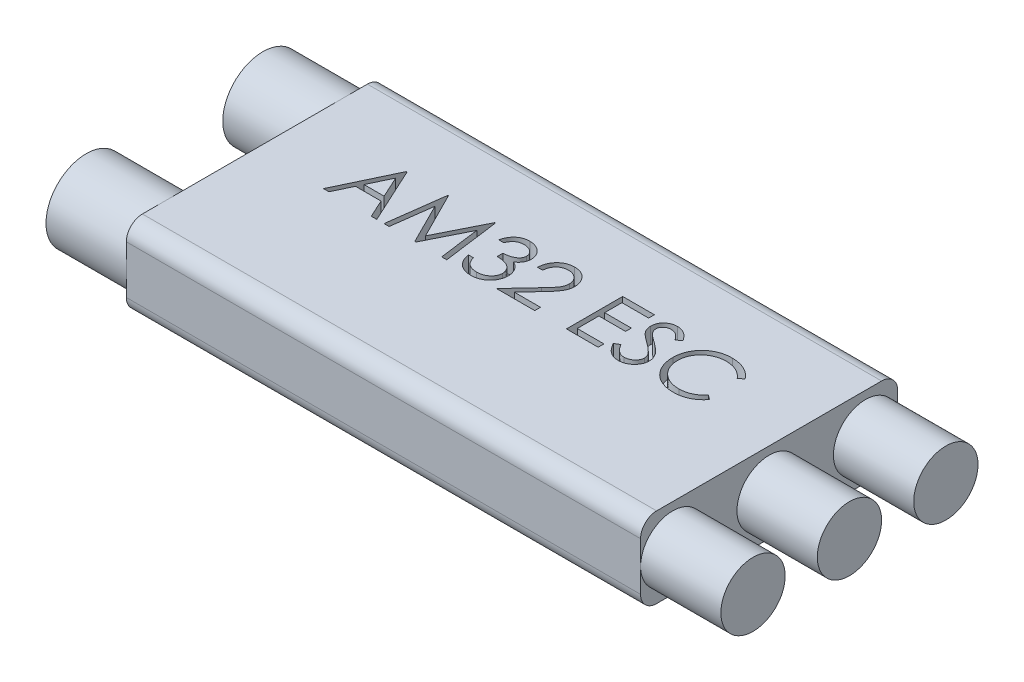
from build123d import *

# Parameters (mm, degrees)
SKETCH1_W           = 32
SKETCH1_H           = 16
BOSS_EXTRUDE1_DEPTH = 5
CUT_EXTRUDE1_DEPTH  = 1
SKETCH3_R           = 2
BOSS_EXTRUDE2_DEPTH = 5
SKETCH4_R           = 2.5
BOSS_EXTRUDE3_DEPTH = 5
FILLET1_R           = 1


with BuildPart() as part:
    # Sketch1 → Boss-Extrude1 (new body)
    with BuildSketch(Plane(origin=(0, 0, 0), x_dir=(1, 0, 0), z_dir=(0, 1, 0))):
        Rectangle(SKETCH1_W, SKETCH1_H)
    extrude(amount=BOSS_EXTRUDE1_DEPTH)

    # Sketch2 → Cut-Extrude1 (cut)
    with BuildSketch(Plane(origin=(0, 5, 0), x_dir=(1, 0, 0), z_dir=(0, 1, 0))):
        Polygon((-10.028846154, 3.5), (-8.413461538, 0), (-8.754907853, 0), (-9.272335737, 1.121794872), (-10.858974359, 1.121794872), (-11.391125801, 0), (-11.733974359, 0), (-10.073717949, 3.5), align=None)
        Polygon((-10.05478766, 2.817808494), (-10.688601763, 1.480769231), (-9.437800481, 1.480769231), align=None, mode=Mode.SUBTRACT)
        Polygon((-7.96474359, 0), (-7.502704327, 3.5), (-7.457832532, 3.5), (-6.012820513, 0.628205128), (-4.571314103, 3.5), (-4.525741186, 3.5), (-4.060897436, 0), (-4.376402244, 0), (-4.711538462, 2.518429487), (-5.974959936, 0), (-6.045773237, 0), (-7.314102564, 2.524038462), (-7.64853766, 0), align=None)
        with BuildLine():
            Line((-3.208333333, 2.692307692), (-3.522435897, 2.692307692))
            add(Edge.make_bspline(
                [(-3.522435897, 2.692307692), (-3.513926347, 2.727540176), (-3.497290871, 2.796416801), (-3.462593298, 2.894824062), (-3.424794043, 2.987947583), (-3.379404938, 3.074043657), (-3.329896184, 3.154842559), (-3.273173462, 3.228511684), (-3.21185374, 3.296924649), (-3.14402879, 3.357637887), (-3.072900129, 3.412615616), (-2.997465509, 3.459490673), (-2.919242615, 3.499814826), (-2.837689482, 3.533035058), (-2.752563311, 3.558060582), (-2.664633687, 3.576217387), (-2.573670187, 3.588008502), (-2.511922597, 3.589159265), (-2.48056891, 3.58974359)],
                knots=[0, 0, 0, 0, 0.000108665, 0.000212431, 0.000312691, 0.000409905, 0.000504067, 0.000596618, 0.000688443, 0.000779278, 0.000869306, 0.00095782, 0.001045306, 0.001133058, 0.001221569, 0.001311085, 0.001402223, 0.001496238, 0.001496238, 0.001496238, 0.001496238], degree=3))
            add(Edge.make_bspline(
                [(-2.48056891, 3.58974359), (-2.434886168, 3.588364359), (-2.344517157, 3.585635984), (-2.21175411, 3.560721548), (-2.083727291, 3.521296415), (-1.961838043, 3.466822688), (-1.848619611, 3.399635375), (-1.747883424, 3.319670638), (-1.660994913, 3.228471337), (-1.588100536, 3.127738772), (-1.531025537, 3.020083263), (-1.488939163, 2.909283106), (-1.463317482, 2.795601134), (-1.459996925, 2.718843855), (-1.458333333, 2.680388622)],
                knots=[0, 0, 0, 0, 0.000136936, 0.000270885, 0.000403723, 0.000538055, 0.000670441, 0.000797677, 0.000922646, 0.001047185, 0.00116951, 0.001287103, 0.001401935, 0.001517226, 0.001517226, 0.001517226, 0.001517226], degree=3))
            add(Edge.make_bspline(
                [(-1.458333333, 2.680388622), (-1.459496924, 2.643381827), (-1.461773891, 2.570965273), (-1.481107597, 2.465243775), (-1.51364386, 2.365602175), (-1.558713623, 2.271621013), (-1.617055173, 2.183896173), (-1.68772787, 2.102230282), (-1.771230531, 2.026261124), (-1.834509469, 1.982741651), (-1.86708734, 1.960336538)],
                knots=[0, 0, 0, 0, 0.000110957, 0.000217125, 0.000321111, 0.000424595, 0.000528824, 0.000636204, 0.000747885, 0.000866393, 0.000866393, 0.000866393, 0.000866393], degree=3))
            add(Edge.make_bspline(
                [(-1.86708734, 1.960336538), (-1.829855585, 1.942358367), (-1.756088711, 1.906738409), (-1.655538181, 1.836882652), (-1.564260306, 1.756226304), (-1.513356587, 1.693283652), (-1.487780449, 1.661658654)],
                knots=[0, 0, 0, 0, 0.000123863, 0.000245408, 0.000366052, 0.000487879, 0.000487879, 0.000487879, 0.000487879], degree=3))
            add(Edge.make_bspline(
                [(-1.487780449, 1.661658654), (-1.470939106, 1.638600902), (-1.43753221, 1.592862986), (-1.396296677, 1.51932656), (-1.358887562, 1.444975071), (-1.329737343, 1.367815664), (-1.307163476, 1.288742651), (-1.291027444, 1.207620255), (-1.281003303, 1.124382232), (-1.279567751, 1.068069752), (-1.278846154, 1.039763622)],
                knots=[0, 0, 0, 0, 8.5583e-05, 0.000169764, 0.000252544, 0.000335098, 0.000416766, 0.000498992, 0.000583001, 0.000667909, 0.000667909, 0.000667909, 0.000667909], degree=3))
            add(Edge.make_bspline(
                [(-1.278846154, 1.039763622), (-1.280640667, 0.990753901), (-1.284221249, 0.892965099), (-1.316225324, 0.748490377), (-1.365838564, 0.607264875), (-1.4362955, 0.472190036), (-1.522163009, 0.345809655), (-1.624320333, 0.232733346), (-1.741606742, 0.135534741), (-1.872412391, 0.054324513), (-2.014129519, -0.010593409), (-2.165705111, -0.055650852), (-2.324955165, -0.084996852), (-2.434162463, -0.08814372), (-2.489683494, -0.08974359)],
                knots=[0, 0, 0, 0, 0.000146863, 0.000293035, 0.000441833, 0.000594857, 0.000748684, 0.000899086, 0.001050437, 0.001204129, 0.001359752, 0.001516561, 0.001677477, 0.001843893, 0.001843893, 0.001843893, 0.001843893], degree=3))
            add(Edge.make_bspline(
                [(-2.489683494, -0.08974359), (-2.527102794, -0.088875376), (-2.600731499, -0.087167022), (-2.708974997, -0.075488421), (-2.812296697, -0.054158416), (-2.910836295, -0.025455111), (-3.004681331, 0.010936632), (-3.093545436, 0.05625533), (-3.17797533, 0.109566832), (-3.257174281, 0.171500419), (-3.331132848, 0.240781759), (-3.397885573, 0.318640769), (-3.458545366, 0.403638173), (-3.511488004, 0.496761229), (-3.559124957, 0.596806487), (-3.598305914, 0.705054985), (-3.632791482, 0.820539007), (-3.648824947, 0.901016747), (-3.657051282, 0.942307692)],
                knots=[0, 0, 0, 0, 0.000112258, 0.000220887, 0.000326076, 0.000428356, 0.000528479, 0.000627563, 0.000727152, 0.000827569, 0.00092875, 0.001030654, 0.001134734, 0.001241526, 0.001351611, 0.001466743, 0.00158655, 0.001712791, 0.001712791, 0.001712791, 0.001712791], degree=3))
            Line((-3.657051282, 0.942307692), (-3.342948718, 0.942307692))
            add(Edge.make_bspline(
                [(-3.342948718, 0.942307692), (-3.334765427, 0.915358679), (-3.318848214, 0.862940507), (-3.291753916, 0.787500202), (-3.260885644, 0.718342149), (-3.227771085, 0.654959027), (-3.192992639, 0.596726624), (-3.154077714, 0.545184755), (-3.113908569, 0.498069553), (-3.083629215, 0.471524941), (-3.068810096, 0.458533654)],
                knots=[0, 0, 0, 0, 8.4487e-05, 0.000164335, 0.000240293, 0.00031148, 0.000378817, 0.000443461, 0.000505064, 0.000564113, 0.000564113, 0.000564113, 0.000564113], degree=3))
            add(Edge.make_bspline(
                [(-3.068810096, 0.458533654), (-3.04921352, 0.44342532), (-3.010080857, 0.413255288), (-2.946312626, 0.37475366), (-2.87924774, 0.341392634), (-2.807433065, 0.315908939), (-2.732418295, 0.294331278), (-2.65299093, 0.280210759), (-2.569851713, 0.270522587), (-2.513083949, 0.269667656), (-2.484074519, 0.269230769)],
                knots=[0, 0, 0, 0, 7.418e-05, 0.000148131, 0.000223072, 0.000298488, 0.0003764, 0.000456984, 0.000540217, 0.000627201, 0.000627201, 0.000627201, 0.000627201], degree=3))
            add(Edge.make_bspline(
                [(-2.484074519, 0.269230769), (-2.451321017, 0.269846674), (-2.38727437, 0.271051024), (-2.29381951, 0.282126731), (-2.204912063, 0.298257144), (-2.121539137, 0.323170127), (-2.04260863, 0.353950979), (-1.96922698, 0.392599384), (-1.900430874, 0.437944106), (-1.837101468, 0.489483264), (-1.780155961, 0.545904759), (-1.730016448, 0.60491783), (-1.687391786, 0.66627366), (-1.653008208, 0.730311781), (-1.625857658, 0.79676701), (-1.607374457, 0.865825839), (-1.594522942, 0.936923105), (-1.59347633, 0.985252074), (-1.592948718, 1.009615385)],
                knots=[0, 0, 0, 0, 9.822e-05, 0.00019206, 0.00028199, 0.000368957, 0.000452673, 0.000535779, 0.000617257, 0.000699492, 0.000780303, 0.000857417, 0.000931514, 0.001003978, 0.001075065, 0.001146335, 0.001218144, 0.001291145, 0.001291145, 0.001291145, 0.001291145], degree=3))
            add(Edge.make_bspline(
                [(-1.592948718, 1.009615385), (-1.594479019, 1.042226723), (-1.597532008, 1.107287132), (-1.620840587, 1.203004706), (-1.659179452, 1.295228118), (-1.712851963, 1.382383909), (-1.778187692, 1.46315981), (-1.854552598, 1.535231293), (-1.942580827, 1.594701384), (-2.023600696, 1.63579004), (-2.095365852, 1.663827115), (-2.156781237, 1.68250208), (-2.22553784, 1.698315735), (-2.300804189, 1.713028007), (-2.383147405, 1.725549355), (-2.472477843, 1.735991171), (-2.568813605, 1.744346212), (-2.635504771, 1.748077307), (-2.669871795, 1.75)],
                knots=[0, 0, 0, 0, 9.7761e-05, 0.000195035, 0.000293731, 0.000396299, 0.00050098, 0.000604654, 0.000710058, 0.000818548, 0.000876487, 0.000941025, 0.001010919, 0.001088059, 0.001171055, 0.001260716, 0.001357836, 0.001461094, 0.001461094, 0.001461094, 0.001461094], degree=3))
            Line((-2.669871795, 1.75), (-2.669871795, 2.108974359))
            add(Edge.make_bspline(
                [(-2.669871795, 2.108974359), (-2.626570629, 2.109709163), (-2.541754283, 2.111148463), (-2.417859978, 2.128556473), (-2.299386666, 2.152637101), (-2.188959924, 2.189522293), (-2.08831121, 2.23236259), (-2.000991608, 2.2822148), (-1.928224461, 2.337629549), (-1.870363389, 2.399462158), (-1.826834161, 2.465777206), (-1.795007363, 2.534893864), (-1.776207037, 2.607417924), (-1.77369737, 2.656912592), (-1.772435897, 2.681790865)],
                knots=[0, 0, 0, 0, 0.0001298, 0.000254247, 0.000374709, 0.000491998, 0.000602842, 0.000702416, 0.000792872, 0.000876214, 0.000955164, 0.001029842, 0.001103644, 0.00117823, 0.00117823, 0.00117823, 0.00117823], degree=3))
            add(Edge.make_bspline(
                [(-1.772435897, 2.681790865), (-1.772850308, 2.700068611), (-1.773674759, 2.736431318), (-1.784072037, 2.789556386), (-1.799696078, 2.841057332), (-1.821175807, 2.890715142), (-1.849926006, 2.938185416), (-1.884331993, 2.983872865), (-1.925300093, 3.027516644), (-1.97224554, 3.068196964), (-2.022657345, 3.106966201), (-2.07790712, 3.139879838), (-2.136328995, 3.1680249), (-2.19798765, 3.191234402), (-2.26308318, 3.20869369), (-2.331309737, 3.221229532), (-2.402797421, 3.229067187), (-2.451569153, 3.230195602), (-2.476362179, 3.230769231)],
                knots=[0, 0, 0, 0, 5.4759e-05, 0.000108941, 0.000161726, 0.000216044, 0.000270754, 0.000327825, 0.00038735, 0.000449943, 0.000514025, 0.000577874, 0.000642472, 0.000708366, 0.000775209, 0.000844379, 0.000916308, 0.00099068, 0.00099068, 0.00099068, 0.00099068], degree=3))
            add(Edge.make_bspline(
                [(-2.476362179, 3.230769231), (-2.516213847, 3.229377869), (-2.594053424, 3.226660215), (-2.706268341, 3.202857202), (-2.810587675, 3.164879118), (-2.890326341, 3.119546099), (-2.949208916, 3.074795665), (-2.991285854, 3.035713279), (-3.032606364, 2.992280455), (-3.070452041, 2.94182208), (-3.108726018, 2.887755289), (-3.143570579, 2.827331608), (-3.177430271, 2.762127214), (-3.197832821, 2.716031579), (-3.208333333, 2.692307692)],
                knots=[0, 0, 0, 0, 0.00011944, 0.000233294, 0.000342435, 0.0004514, 0.000506931, 0.000563998, 0.000623523, 0.000686492, 0.000753006, 0.000822147, 0.000895524, 0.000973336, 0.000973336, 0.000973336, 0.000973336], degree=3))
        make_face()
        with BuildLine():
            Line((-0.516025641, 2.423076923), (-0.830128205, 2.423076923))
            add(Edge.make_bspline(
                [(-0.830128205, 2.423076923), (-0.828081052, 2.464747811), (-0.824060498, 2.546588325), (-0.805232209, 2.665912232), (-0.778291332, 2.779967031), (-0.740199878, 2.887836945), (-0.6928936, 2.990475752), (-0.636163572, 3.087475767), (-0.568969722, 3.178466956), (-0.492762988, 3.262605799), (-0.409994349, 3.33979337), (-0.320688409, 3.406448613), (-0.226843382, 3.462766284), (-0.128743983, 3.509847526), (-0.02528342, 3.545187372), (0.082599438, 3.571409012), (0.195378575, 3.587185357), (0.272218597, 3.588881143), (0.311298077, 3.58974359)],
                knots=[0, 0, 0, 0, 0.000125083, 0.00024566, 0.000361805, 0.000476223, 0.000588214, 0.000700404, 0.000812728, 0.00092691, 0.001040529, 0.001151727, 0.001260545, 0.001368429, 0.001477521, 0.001587884, 0.001701119, 0.00181831, 0.00181831, 0.00181831, 0.00181831], degree=3))
            add(Edge.make_bspline(
                [(0.311298077, 3.58974359), (0.349676151, 3.588845133), (0.425087696, 3.587079698), (0.53514971, 3.571918669), (0.639927005, 3.548173078), (0.739214771, 3.514857661), (0.832220836, 3.470073234), (0.91964388, 3.416275695), (1.002524691, 3.354055864), (1.077131475, 3.28080205), (1.145639554, 3.202599666), (1.204741809, 3.119111762), (1.255354972, 3.032882477), (1.297542652, 2.943254275), (1.328598791, 2.849383247), (1.352176999, 2.752636044), (1.365504413, 2.652011233), (1.367549837, 2.583904677), (1.368589744, 2.549278846)],
                knots=[0, 0, 0, 0, 0.000115089, 0.000226145, 0.000332614, 0.000437044, 0.000539592, 0.000641561, 0.000744629, 0.00084975, 0.000954621, 0.001056175, 0.001156101, 0.001254284, 0.001352726, 0.001452208, 0.001552655, 0.001656537, 0.001656537, 0.001656537, 0.001656537], degree=3))
            add(Edge.make_bspline(
                [(1.368589744, 2.549278846), (1.366896481, 2.500531012), (1.363539669, 2.403890798), (1.334825293, 2.261875935), (1.289978782, 2.124282516), (1.235981425, 2.013545214), (1.181508981, 1.92431172), (1.132421473, 1.850843015), (1.074956662, 1.771737547), (1.008278164, 1.68726021), (0.933765292, 1.596749304), (0.850743129, 1.500259509), (0.758619647, 1.398787739), (0.693961146, 1.329482138), (0.660456731, 1.293569712)],
                knots=[0, 0, 0, 0, 0.000146118, 0.000289672, 0.0004329, 0.00057934, 0.000657978, 0.000746456, 0.000844345, 0.000951219, 0.001069268, 0.00119604, 0.001333047, 0.001480391, 0.001480391, 0.001480391, 0.001480391], degree=3))
            Line((0.660456731, 1.293569712), (-0.215244391, 0.358974359))
            Line((-0.215244391, 0.358974359), (1.413461538, 0.358974359))
            Line((1.413461538, 0.358974359), (1.413461538, 0))
            Line((1.413461538, 0), (-0.96474359, 0))
            Line((-0.96474359, 0), (0.392628205, 1.448517628))
            add(Edge.make_bspline(
                [(0.392628205, 1.448517628), (0.425676092, 1.483015935), (0.489154319, 1.549280121), (0.578936896, 1.646023081), (0.659575884, 1.735772622), (0.731593277, 1.818359171), (0.793426782, 1.894990738), (0.848299014, 1.963185442), (0.892264605, 2.025939892), (0.939980001, 2.098680506), (0.986193982, 2.187492823), (1.025906338, 2.296026513), (1.050121187, 2.407753765), (1.053026022, 2.483255802), (1.054487179, 2.521233974)],
                knots=[0, 0, 0, 0, 0.000143319, 0.000275286, 0.00039593, 0.000505287, 0.000603949, 0.000691331, 0.000767782, 0.00083371, 0.000952247, 0.001067137, 0.001179618, 0.001293462, 0.001293462, 0.001293462, 0.001293462], degree=3))
            add(Edge.make_bspline(
                [(1.054487179, 2.521233974), (1.053851437, 2.545115373), (1.052598511, 2.592181023), (1.041540814, 2.661186782), (1.024830308, 2.727751596), (1.00088505, 2.792080215), (0.969278309, 2.853525867), (0.93080493, 2.912163347), (0.886414866, 2.968852313), (0.835063597, 3.022005611), (0.778652077, 3.070686816), (0.719057827, 3.113810902), (0.656007723, 3.149850012), (0.589767601, 3.179393509), (0.520522132, 3.202568891), (0.448137386, 3.21862747), (0.37281337, 3.228709954), (0.321379874, 3.230074126), (0.295172276, 3.230769231)],
                knots=[0, 0, 0, 0, 7.16e-05, 0.00014111, 0.00020913, 0.00027724, 0.000346538, 0.000415963, 0.000487357, 0.000562233, 0.000637292, 0.000710646, 0.000782564, 0.000854749, 0.000927915, 0.001001225, 0.001076884, 0.001155488, 0.001155488, 0.001155488, 0.001155488], degree=3))
            add(Edge.make_bspline(
                [(0.295172276, 3.230769231), (0.267801443, 3.230054199), (0.214049647, 3.228649993), (0.135130614, 3.218827329), (0.059844836, 3.201881489), (-0.011997067, 3.178704814), (-0.080516653, 3.149246266), (-0.145380697, 3.112554521), (-0.206443586, 3.068771028), (-0.263820109, 3.019130471), (-0.316684088, 2.96386287), (-0.363130964, 2.902252907), (-0.403714978, 2.835425492), (-0.439124212, 2.763560941), (-0.467879902, 2.686007161), (-0.489853052, 2.603039456), (-0.507239899, 2.515018075), (-0.51304842, 2.45423299), (-0.516025641, 2.423076923)],
                knots=[0, 0, 0, 0, 8.2106e-05, 0.000161243, 0.000238127, 0.000313291, 0.000387401, 0.000461495, 0.000536397, 0.000612445, 0.000688819, 0.000765383, 0.000843422, 0.000923066, 0.001005373, 0.001091093, 0.001180334, 0.001274175, 0.001274175, 0.001274175, 0.001274175], degree=3))
        make_face()
        Polygon((3.387820513, 3.5), (5.362179487, 3.5), (5.362179487, 3.141025641), (3.701923077, 3.141025641), (3.701923077, 2.064102564), (5.362179487, 2.064102564), (5.362179487, 1.705128205), (3.701923077, 1.705128205), (3.701923077, 0.358974359), (5.362179487, 0.358974359), (5.362179487, 0), (3.387820513, 0), align=None)
        with BuildLine():
            Line((5.631410256, 0.675180288), (5.927283654, 0.852564103))
            add(Edge.make_bspline(
                [(5.927283654, 0.852564103), (5.954801891, 0.806499718), (6.007525772, 0.718242134), (6.095477131, 0.598984093), (6.186610042, 0.497621937), (6.281599376, 0.414745329), (6.379865324, 0.349496442), (6.482049377, 0.303294211), (6.587807188, 0.274478235), (6.65978101, 0.270978149), (6.695713141, 0.269230769)],
                knots=[0, 0, 0, 0, 0.000160901, 0.00030828, 0.000443778, 0.00056903, 0.000685513, 0.000796284, 0.00090427, 0.001011928, 0.001011928, 0.001011928, 0.001011928], degree=3))
            add(Edge.make_bspline(
                [(6.695713141, 0.269230769), (6.726400002, 0.270085442), (6.787236775, 0.271779832), (6.876799018, 0.288060634), (6.96378082, 0.313072763), (7.046389458, 0.348893694), (7.123485072, 0.39223218), (7.191091767, 0.444578358), (7.249537881, 0.503184563), (7.297346995, 0.568567218), (7.33402703, 0.638884367), (7.362219099, 0.711060318), (7.377864173, 0.786228886), (7.380220926, 0.836839349), (7.381410256, 0.862379808)],
                knots=[0, 0, 0, 0, 9.1978e-05, 0.000182347, 0.000272202, 0.000362975, 0.000451852, 0.000536835, 0.000618639, 0.000699414, 0.000778765, 0.000855983, 0.0009312, 0.001007828, 0.001007828, 0.001007828, 0.001007828], degree=3))
            add(Edge.make_bspline(
                [(7.381410256, 0.862379808), (7.379935946, 0.891520657), (7.376938887, 0.950759747), (7.351607407, 1.0381594), (7.311758161, 1.12465197), (7.274995517, 1.178153235), (7.255909455, 1.205929487)],
                knots=[0, 0, 0, 0, 8.7281e-05, 0.000177429, 0.000270909, 0.000371844, 0.000371844, 0.000371844, 0.000371844], degree=3))
            add(Edge.make_bspline(
                [(7.255909455, 1.205929487), (7.240238841, 1.225976311), (7.207340347, 1.268062109), (7.150782834, 1.330707345), (7.08441672, 1.395325764), (7.010513165, 1.464384821), (6.926380076, 1.534672617), (6.834652562, 1.609540895), (6.732988703, 1.686142472), (6.661689206, 1.737515038), (6.62489984, 1.764022436)],
                knots=[0, 0, 0, 0, 7.6319e-05, 0.000160223, 0.000252933, 0.000354147, 0.000463581, 0.000581729, 0.000709336, 0.000845369, 0.000845369, 0.000845369, 0.000845369], degree=3))
            add(Edge.make_bspline(
                [(6.62489984, 1.764022436), (6.588075844, 1.790251024), (6.517671167, 1.840398086), (6.419212585, 1.91482237), (6.331168122, 1.982866239), (6.253929105, 2.045170251), (6.187529508, 2.101742856), (6.131446097, 2.152040795), (6.08710754, 2.197424356), (6.062451959, 2.226865698), (6.051382212, 2.240084135)],
                knots=[0, 0, 0, 0, 0.000135623, 0.000259301, 0.000370234, 0.000469439, 0.00055697, 0.000631911, 0.000695377, 0.00074709, 0.00074709, 0.00074709, 0.00074709], degree=3))
            add(Edge.make_bspline(
                [(6.051382212, 2.240084135), (6.035909666, 2.260685171), (6.00548083, 2.301199875), (5.965314824, 2.364524733), (5.931175661, 2.429347998), (5.904413329, 2.495843863), (5.88187711, 2.563078792), (5.86671918, 2.631930038), (5.857227783, 2.702088656), (5.856255796, 2.749302157), (5.855769231, 2.772936699)],
                knots=[0, 0, 0, 0, 7.727e-05, 0.000151962, 0.000224716, 0.000296717, 0.00036678, 0.0004372, 0.000507902, 0.000578771, 0.000578771, 0.000578771, 0.000578771], degree=3))
            add(Edge.make_bspline(
                [(5.855769231, 2.772936699), (5.85707444, 2.809966473), (5.85965696, 2.883234537), (5.881497477, 2.990265367), (5.915970371, 3.092451785), (5.964265259, 3.188782118), (6.026522612, 3.276748099), (6.098568586, 3.357361586), (6.184380072, 3.425130168), (6.278532695, 3.484342227), (6.381589067, 3.530688152), (6.489579971, 3.565649132), (6.602677043, 3.58545839), (6.679280178, 3.588301155), (6.718149038, 3.58974359)],
                knots=[0, 0, 0, 0, 0.000110999, 0.000219625, 0.000326272, 0.00043382, 0.000541574, 0.000648775, 0.000756959, 0.000868438, 0.000981703, 0.00109501, 0.001208203, 0.0013248, 0.0013248, 0.0013248, 0.0013248], degree=3))
            add(Edge.make_bspline(
                [(6.718149038, 3.58974359), (6.759393139, 3.588321038), (6.841414491, 3.585492037), (6.962063706, 3.560894506), (7.078224422, 3.520193834), (7.171667687, 3.474005176), (7.244800449, 3.42787376), (7.300573181, 3.385853936), (7.357090632, 3.337478827), (7.414808687, 3.282619581), (7.472749347, 3.22077283), (7.531772799, 3.152362141), (7.592017068, 3.077805585), (7.630772928, 3.024581085), (7.650641026, 2.997295673)],
                knots=[0, 0, 0, 0, 0.000123638, 0.000245877, 0.000367608, 0.000492088, 0.000557638, 0.000626769, 0.000701372, 0.00078072, 0.000865532, 0.000955497, 0.001051745, 0.001152989, 0.001152989, 0.001152989, 0.001152989], degree=3))
            Line((7.650641026, 2.997295673), (7.366686699, 2.782051282))
            add(Edge.make_bspline(
                [(7.366686699, 2.782051282), (7.349540766, 2.804139972), (7.316521709, 2.846677626), (7.266392222, 2.906248941), (7.219143574, 2.960665421), (7.172593175, 3.007930549), (7.129199543, 3.050632682), (7.087082501, 3.087192439), (7.04684815, 3.117968034), (6.996131239, 3.150811594), (6.932413521, 3.183368098), (6.852428984, 3.210917176), (6.768842709, 3.227472238), (6.711913078, 3.229661126), (6.683092949, 3.230769231)],
                knots=[0, 0, 0, 0, 8.3877e-05, 0.000161528, 0.000233552, 0.000299993, 0.000360485, 0.000416152, 0.000467195, 0.000512312, 0.000597287, 0.000681099, 0.000765389, 0.000851809, 0.000851809, 0.000851809, 0.000851809], degree=3))
            add(Edge.make_bspline(
                [(6.683092949, 3.230769231), (6.646936426, 3.229557531), (6.577211979, 3.227220882), (6.478221743, 3.201700896), (6.389127818, 3.161519036), (6.312575253, 3.105204058), (6.248838276, 3.038483065), (6.202732817, 2.96170421), (6.174982652, 2.876921808), (6.171596373, 2.817780151), (6.169871795, 2.787660256)],
                knots=[0, 0, 0, 0, 0.000108248, 0.000208746, 0.00030443, 0.000399793, 0.000492054, 0.00057947, 0.000666386, 0.000756591, 0.000756591, 0.000756591, 0.000756591], degree=3))
            add(Edge.make_bspline(
                [(6.169871795, 2.787660256), (6.170264922, 2.768908778), (6.171051818, 2.731375158), (6.182026615, 2.675923736), (6.196125944, 2.620612397), (6.218468576, 2.565689814), (6.24931388, 2.510195455), (6.289819056, 2.453173718), (6.340832368, 2.394122009), (6.37990938, 2.355714635), (6.400540865, 2.335436699)],
                knots=[0, 0, 0, 0, 5.616e-05, 0.000112411, 0.000169046, 0.000227244, 0.000289691, 0.000359134, 0.000436702, 0.000523463, 0.000523463, 0.000523463, 0.000523463], degree=3))
            add(Edge.make_bspline(
                [(6.400540865, 2.335436699), (6.408202238, 2.328599673), (6.426403905, 2.312356465), (6.459679831, 2.285764184), (6.503622629, 2.252961412), (6.55708483, 2.212374095), (6.621052192, 2.165292633), (6.695531748, 2.112319021), (6.779693281, 2.051733562), (6.839415197, 2.009376021), (6.87099359, 1.986979167)],
                knots=[0, 0, 0, 0, 3.0802e-05, 7.3177e-05, 0.000127725, 0.000195314, 0.000274544, 0.000365991, 0.000469501, 0.000585644, 0.000585644, 0.000585644, 0.000585644], degree=3))
            add(Edge.make_bspline(
                [(6.87099359, 1.986979167), (6.908979503, 1.959337807), (6.982533959, 1.905814145), (7.087191539, 1.825398465), (7.182085347, 1.746750697), (7.267548551, 1.67037309), (7.344425459, 1.596844997), (7.41186318, 1.525281816), (7.47054886, 1.456196244), (7.533728079, 1.367623668), (7.598285898, 1.258842584), (7.653727406, 1.125564345), (7.688685753, 0.991768025), (7.693257269, 0.901841188), (7.695512821, 0.857471955)],
                knots=[0, 0, 0, 0, 0.000140932, 0.000272896, 0.000395881, 0.000510584, 0.000616697, 0.000714904, 0.000805482, 0.000888372, 0.001041088, 0.001183793, 0.001320341, 0.001453327, 0.001453327, 0.001453327, 0.001453327], degree=3))
            add(Edge.make_bspline(
                [(7.695512821, 0.857471955), (7.694855682, 0.82609359), (7.693554167, 0.763946206), (7.678593254, 0.67269113), (7.656673588, 0.58406026), (7.623636354, 0.499149147), (7.583313196, 0.416404385), (7.532146948, 0.337996484), (7.472839264, 0.262190086), (7.404805499, 0.191006594), (7.330359596, 0.125660398), (7.251675902, 0.067531337), (7.168625629, 0.019063014), (7.081659312, -0.020487828), (6.990756975, -0.051421346), (6.895949192, -0.073834215), (6.79707968, -0.087589926), (6.729879199, -0.089017687), (6.695713141, -0.08974359)],
                knots=[0, 0, 0, 0, 9.4044e-05, 0.000186263, 0.000276729, 0.000367488, 0.000459046, 0.000552398, 0.000647774, 0.000747454, 0.000847311, 0.000944634, 0.001040472, 0.001135227, 0.001230788, 0.001328063, 0.00142712, 0.00152957, 0.00152957, 0.00152957, 0.00152957], degree=3))
            add(Edge.make_bspline(
                [(6.695713141, -0.08974359), (6.669277798, -0.089232408), (6.616740038, -0.088216483), (6.539030556, -0.079235202), (6.462890967, -0.066528099), (6.389276685, -0.046354029), (6.317239273, -0.021877052), (6.247092039, 0.008261281), (6.178800985, 0.044378482), (6.111983402, 0.085673507), (6.046809227, 0.133731252), (5.983889759, 0.189704748), (5.921160574, 0.252050253), (5.860473178, 0.322460816), (5.800600033, 0.399798899), (5.742721624, 0.484788083), (5.685639906, 0.576965436), (5.649824438, 0.641830522), (5.631410256, 0.675180288)],
                knots=[0, 0, 0, 0, 7.9276e-05, 0.000157554, 0.000234438, 0.000310629, 0.000386236, 0.000462555, 0.000539392, 0.000617798, 0.000698008, 0.000781971, 0.000870217, 0.00096315, 0.001060616, 0.001163492, 0.001271478, 0.00138575, 0.00138575, 0.00138575, 0.00138575], degree=3))
        make_face()
        with BuildLine():
            Line((11.644230769, 2.857772436), (11.369391026, 2.647435897))
            add(Edge.make_bspline(
                [(11.369391026, 2.647435897), (11.349785137, 2.670801867), (11.31083769, 2.717218783), (11.248178488, 2.782398327), (11.182876845, 2.843463589), (11.114957724, 2.900705469), (11.043198604, 2.952122234), (10.969337806, 3.000393337), (10.89213976, 3.043661075), (10.785388026, 3.096124061), (10.645740178, 3.150870216), (10.469945338, 3.196773448), (10.28643424, 3.225994623), (10.16123664, 3.229159465), (10.09755609, 3.230769231)],
                knots=[0, 0, 0, 0, 9.1485e-05, 0.000181737, 0.000271024, 0.000359627, 0.000447979, 0.000535687, 0.000624217, 0.000713268, 0.000892422, 0.00107303, 0.001257466, 0.001448389, 0.001448389, 0.001448389, 0.001448389], degree=3))
            add(Edge.make_bspline(
                [(10.09755609, 3.230769231), (10.06247279, 3.230365268), (9.992631798, 3.229561092), (9.888983324, 3.218951967), (9.787270273, 3.204040757), (9.687558807, 3.181915434), (9.589975848, 3.153942815), (9.493883446, 3.120517401), (9.400672847, 3.079162561), (9.309054608, 3.033454301), (9.221275397, 2.981826856), (9.13822035, 2.925513504), (9.060192382, 2.865144408), (8.98712977, 2.800493302), (8.918957821, 2.731851341), (8.85617051, 2.658487), (8.7989851, 2.580634826), (8.746268075, 2.499321419), (8.699055342, 2.414783627), (8.659525462, 2.326708556), (8.62452034, 2.236604453), (8.596821097, 2.143453293), (8.574896581, 2.047910527), (8.559768917, 1.949719739), (8.549280446, 1.849086059), (8.548480269, 1.780876747), (8.548076923, 1.746494391)],
                knots=[0, 0, 0, 0, 0.000105206, 0.000209435, 0.000312261, 0.00041348, 0.000515565, 0.000616682, 0.000718413, 0.000821258, 0.000923708, 0.001023662, 0.001122111, 0.001219464, 0.00131614, 0.001412112, 0.001508869, 0.001605718, 0.001702691, 0.001799013, 0.001895107, 0.001992482, 0.002090281, 0.00218895, 0.002290387, 0.00239349, 0.00239349, 0.00239349, 0.00239349], degree=3))
            add(Edge.make_bspline(
                [(8.548076923, 1.746494391), (8.549338742, 1.694763071), (8.551816156, 1.593195486), (8.57386449, 1.444424876), (8.607369582, 1.301904202), (8.657585159, 1.16652436), (8.719504209, 1.036616002), (8.797744821, 0.914377148), (8.888361358, 0.797960584), (8.992635778, 0.690117636), (9.107041594, 0.591603911), (9.229789505, 0.504853329), (9.360573793, 0.432538447), (9.497950423, 0.3723625), (9.642976537, 0.326105772), (9.795391339, 0.293541649), (9.954863335, 0.272299468), (10.063832735, 0.27026578), (10.119290865, 0.269230769)],
                knots=[0, 0, 0, 0, 0.000155106, 0.000304531, 0.000450265, 0.000593548, 0.000736853, 0.000881182, 0.001028026, 0.001178769, 0.001330408, 0.001480379, 0.001628835, 0.001777978, 0.001929641, 0.002084627, 0.002245075, 0.00241136, 0.00241136, 0.00241136, 0.00241136], degree=3))
            add(Edge.make_bspline(
                [(10.119290865, 0.269230769), (10.180393554, 0.270919549), (10.300658263, 0.274243472), (10.47702629, 0.302402721), (10.645862055, 0.348060638), (10.807174642, 0.411958561), (10.960509288, 0.495023849), (11.106105948, 0.595721726), (11.244087519, 0.715010059), (11.327058801, 0.806093187), (11.369391026, 0.852564103)],
                knots=[0, 0, 0, 0, 0.00018322, 0.00036062, 0.000534275, 0.000707044, 0.000879893, 0.001056289, 0.001237208, 0.001425665, 0.001425665, 0.001425665, 0.001425665], degree=3))
            Line((11.369391026, 0.852564103), (11.644230769, 0.644330929))
            add(Edge.make_bspline(
                [(11.644230769, 0.644330929), (11.622112659, 0.615792478), (11.577982384, 0.558852271), (11.506524367, 0.478580562), (11.43124707, 0.403076526), (11.35159136, 0.332948905), (11.268473568, 0.266794439), (11.180401256, 0.206492608), (11.088532223, 0.151201724), (10.993177744, 0.100574799), (10.894439132, 0.055657552), (10.792434697, 0.017203784), (10.687604121, -0.015921105), (10.579942613, -0.043173042), (10.469226856, -0.064444126), (10.355856382, -0.078663801), (10.239586507, -0.088405715), (10.161145085, -0.089293631), (10.121394231, -0.08974359)],
                knots=[0, 0, 0, 0, 0.000108293, 0.000216068, 0.000322162, 0.000427957, 0.000534281, 0.00064066, 0.000747915, 0.000855806, 0.000964371, 0.001073102, 0.001182643, 0.001294024, 0.001406092, 0.001520624, 0.001636667, 0.001755891, 0.001755891, 0.001755891, 0.001755891], degree=3))
            add(Edge.make_bspline(
                [(10.121394231, -0.08974359), (10.083750564, -0.089481597), (10.009314874, -0.088963539), (9.899416122, -0.080571372), (9.792426541, -0.069121635), (9.688651915, -0.051881504), (9.58752594, -0.031537164), (9.489965356, -0.004265907), (9.395010145, 0.026283259), (9.303041805, 0.062188246), (9.213982105, 0.102704429), (9.128118294, 0.148495987), (9.045489861, 0.199177852), (8.96528444, 0.253632863), (8.888686857, 0.313610164), (8.815033331, 0.378276799), (8.743910855, 0.44741481), (8.69990817, 0.497269663), (8.677784455, 0.522335737)],
                knots=[0, 0, 0, 0, 0.0001129, 0.000223246, 0.000330481, 0.000435603, 0.000538732, 0.000639764, 0.000739316, 0.000837878, 0.000935767, 0.001032686, 0.001129604, 0.00122645, 0.001323362, 0.001421241, 0.001520399, 0.001620667, 0.001620667, 0.001620667, 0.001620667], degree=3))
            add(Edge.make_bspline(
                [(8.677784455, 0.522335737), (8.642348812, 0.565876926), (8.571905335, 0.652433637), (8.481779651, 0.792719618), (8.404632096, 0.939187827), (8.342256175, 1.092607755), (8.293493442, 1.252635143), (8.259712247, 1.419350657), (8.237760643, 1.592598599), (8.235250354, 1.710435388), (8.233974359, 1.770332532)],
                knots=[0, 0, 0, 0, 0.000168306, 0.00033458, 0.000499224, 0.000664315, 0.00083066, 0.00100034, 0.001174094, 0.001353718, 0.001353718, 0.001353718, 0.001353718], degree=3))
            add(Edge.make_bspline(
                [(8.233974359, 1.770332532), (8.235529553, 1.833287986), (8.238589299, 1.95714891), (8.264585094, 2.138922863), (8.30640389, 2.313074262), (8.365800779, 2.479278007), (8.44110613, 2.638408287), (8.534132744, 2.789249492), (8.643799886, 2.932766292), (8.769247454, 3.066781043), (8.906814789, 3.189320396), (9.054133603, 3.297126599), (9.21091555, 3.386844115), (9.375433402, 3.461840278), (9.548919083, 3.519484741), (9.731002453, 3.559837928), (9.921341367, 3.584955044), (10.051203793, 3.588130252), (10.1171875, 3.58974359)],
                knots=[0, 0, 0, 0, 0.000188789, 0.000371431, 0.000549644, 0.000725278, 0.00089996, 0.001076844, 0.001255917, 0.001440951, 0.001626689, 0.001807878, 0.001987546, 0.002167657, 0.002349462, 0.002534866, 0.002726448, 0.002924344, 0.002924344, 0.002924344, 0.002924344], degree=3))
            add(Edge.make_bspline(
                [(10.1171875, 3.58974359), (10.157401972, 3.589261452), (10.237002469, 3.588307108), (10.354755122, 3.579000965), (10.469397449, 3.563487359), (10.581008431, 3.542371289), (10.690131047, 3.516163968), (10.795931288, 3.48202367), (10.899029975, 3.442987138), (10.998776883, 3.398028672), (11.094693433, 3.347561931), (11.186749751, 3.292146307), (11.27421461, 3.231850502), (11.357703459, 3.167187326), (11.43581967, 3.096788767), (11.510781148, 3.022591171), (11.580042226, 2.942457347), (11.622795421, 2.886052413), (11.644230769, 2.857772436)],
                knots=[0, 0, 0, 0, 0.000120626, 0.000238766, 0.000354085, 0.000467531, 0.000579423, 0.000690512, 0.000800803, 0.000910007, 0.001018518, 0.001125773, 0.001232152, 0.001337058, 0.001442329, 0.001547432, 0.001653292, 0.001759736, 0.001759736, 0.001759736, 0.001759736], degree=3))
        make_face()
    extrude(amount=-CUT_EXTRUDE1_DEPTH, mode=Mode.SUBTRACT)

    # Sketch3 → Boss-Extrude2 (add)
    with BuildSketch(Plane(origin=(16, 0, 0), x_dir=(0, 0, -1), z_dir=(1, 0, 0))):
        with Locations((-6, 2.5)):
            Circle(SKETCH3_R)
        with Locations((0, 2.5)):
            Circle(SKETCH3_R)
        with Locations((6, 2.5)):
            Circle(SKETCH3_R)
    extrude(amount=BOSS_EXTRUDE2_DEPTH)

    # Sketch4 → Boss-Extrude3 (add)
    with BuildSketch(Plane.ZY.offset(16)):
        with Locations((-5.5, 2.5)):
            Circle(SKETCH4_R)
        with Locations((5.5, 2.5)):
            Circle(SKETCH4_R)
    extrude(amount=BOSS_EXTRUDE3_DEPTH)

    # Fillet1
    fillet1_edges = [part.edges().sort_by_distance(p)[0] for p in [
        (0, 5, 8),
        (0, 0, 8),
        (0, 0, -8),
        (0, 5, -8),
    ]]
    fillet(fillet1_edges, radius=FILLET1_R)


solid = part.part
